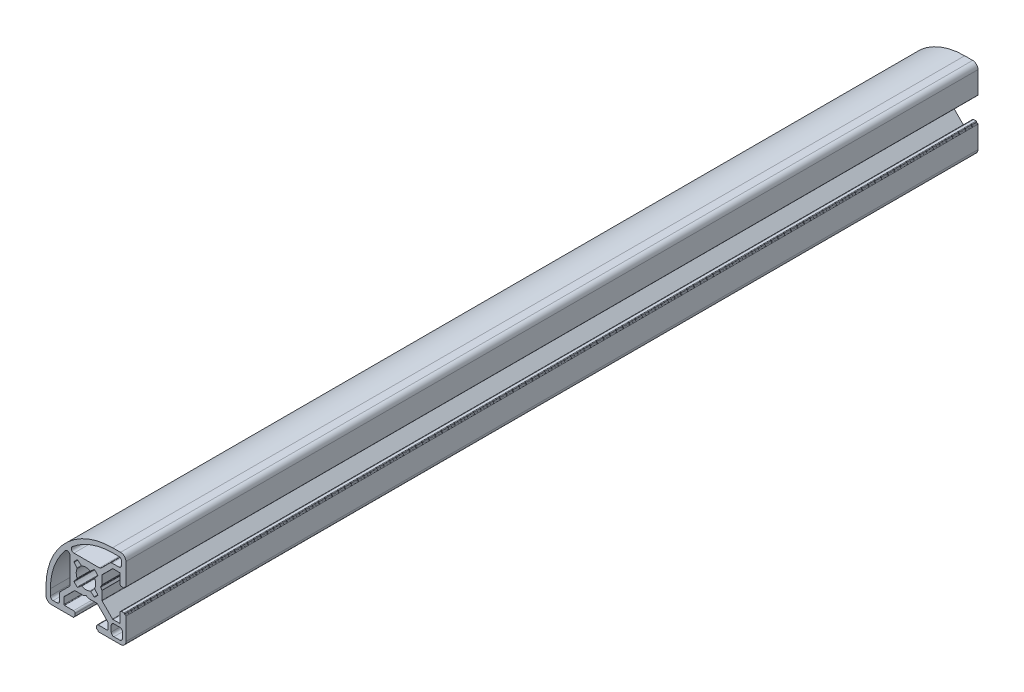
from build123d import *

# Parameters (mm, degrees)
EXTRUDE_1_DEPTH = 320


with BuildPart() as part:
    # Эскиз1 → Бобышка-Вытянуть1 (new body)
    with BuildSketch(Plane.XY):
        with BuildLine():
            Line((5.977671173, -0.853590033), (5.542585895, -0.100000184))
            ThreePointArc((5.542585895, -0.100000184), (5.515790979, -1.84e-07), (5.5425859, 0.099999816))
            Line((5.5425859, 0.099999816), (5.977671215, 0.853589644))
            ThreePointArc((5.977671215, 0.853589644), (5.9976513, 0.901825834), (6.004466136, 0.953589643))
            Line((6.004466136, 0.953589643), (6.004466136, 4.121623186))
            ThreePointArc((6.004466136, 4.121623186), (6.019690232, 4.198159872), (6.063044784, 4.263044541))
            Line((6.063044784, 4.263044541), (9.991421498, 8.191421063))
            ThreePointArc((9.991421498, 8.191421063), (10.056306169, 8.234775612), (10.132842855, 8.249999704))
            Line((10.132842855, 8.249999704), (12.600000143, 8.249999704))
            ThreePointArc((12.600000143, 8.249999704), (12.741421498, 8.191421057), (12.800000138, 8.049999699))
            Line((12.800000138, 8.049999699), (12.800000138, 4.649999699))
            ThreePointArc((12.800000138, 4.649999699), (12.975736059, 4.225735626), (13.400000123, 4.049999684))
            Line((13.400000123, 4.049999684), (14.300000123, 4.049999684))
            ThreePointArc((14.300000123, 4.049999684), (14.441421481, 4.108578325), (14.500000128, 4.249999679))
            Line((14.500000128, 4.249999679), (14.500000128, 4.349999679))
            ThreePointArc((14.500000128, 4.349999679), (14.558578775, 4.491421034), (14.700000133, 4.549999675))
            Line((14.700000133, 4.549999675), (14.800000133, 4.549999675))
            ThreePointArc((14.800000133, 4.549999675), (14.941421467, 4.608578371), (15.000000058, 4.749999749))
            Line((15.000000058, 4.749999749), (15.000000259, 12.999999749))
            ThreePointArc((15.000000259, 12.999999749), (14.414213856, 14.414213326), (13.000000308, 14.999999798))
            Line((13.000000308, 14.999999798), (10.000000308, 14.999999798))
            ThreePointArc((10.000000308, 14.999999798), (-7.6776694, 7.677669758), (-15.000000301, -9.999999593))
            Line((-15.000000301, -9.999999593), (-15.000000301, -12.999999593))
            ThreePointArc((-15.000000301, -12.999999593), (-14.414213898, -14.41421317), (-13.00000035, -14.999999642))
            Line((-13.00000035, -14.999999642), (-4.75000035, -14.999999843))
            ThreePointArc((-4.75000035, -14.999999843), (-4.608578992, -14.941421202), (-4.550000345, -14.799999848))
            Line((-4.550000345, -14.799999848), (-4.550000345, -14.699999848))
            ThreePointArc((-4.550000345, -14.699999848), (-4.491421698, -14.558578493), (-4.35000034, -14.499999852))
            Line((-4.35000034, -14.499999852), (-4.25000034, -14.499999852))
            ThreePointArc((-4.25000034, -14.499999852), (-4.108578982, -14.441421212), (-4.050000335, -14.299999857))
            Line((-4.050000335, -14.299999857), (-4.050000335, -13.399999857))
            ThreePointArc((-4.050000335, -13.399999857), (-4.225736256, -12.975735784), (-4.65000032, -12.799999843))
            Line((-4.65000032, -12.799999843), (-8.05000032, -12.799999843))
            ThreePointArc((-8.05000032, -12.799999843), (-8.191421675, -12.741421195), (-8.250000316, -12.599999838))
            Line((-8.250000316, -12.599999838), (-8.250000316, -10.13284255))
            ThreePointArc((-8.250000316, -10.13284255), (-8.23477622, -10.056305864), (-8.191421668, -9.991421195))
            Line((-8.191421668, -9.991421195), (-4.263044954, -6.063044673))
            ThreePointArc((-4.263044954, -6.063044673), (-4.198160283, -6.019690124), (-4.121623597, -6.004466032))
            Line((-4.121623597, -6.004466032), (-0.953590053, -6.004466032))
            ThreePointArc((-0.953590053, -6.004466032), (-0.901826244, -5.997651199), (-0.853590053, -5.977671116))
            Line((-0.853590053, -5.977671116), (-0.100000204, -5.542585838))
            ThreePointArc((-0.100000204, -5.542585838), (-2.03e-07, -5.515790921), (0.099999796, -5.542585843))
            Line((0.099999796, -5.542585843), (0.853589624, -5.977671157))
            ThreePointArc((0.853589624, -5.977671157), (0.901825815, -5.997651243), (0.953589624, -6.004466079))
            Line((0.953589624, -6.004466079), (4.121623167, -6.004466079))
            ThreePointArc((4.121623167, -6.004466079), (4.198159853, -6.019690174), (4.263044521, -6.063044726))
            Line((4.263044521, -6.063044726), (8.191421044, -9.99142144))
            ThreePointArc((8.191421044, -9.99142144), (8.234775593, -10.056306111), (8.249999684, -10.132842798))
            Line((8.249999684, -10.132842798), (8.249999684, -12.600000085))
            ThreePointArc((8.249999684, -12.600000085), (8.191421037, -12.74142144), (8.04999968, -12.800000081))
            Line((8.04999968, -12.800000081), (4.64999968, -12.800000081))
            ThreePointArc((4.64999968, -12.800000081), (4.225735607, -12.975736002), (4.049999665, -13.400000066))
            Line((4.049999665, -13.400000066), (4.049999665, -14.300000066))
            ThreePointArc((4.049999665, -14.300000066), (4.108578305, -14.441421424), (4.24999966, -14.500000071))
            Line((4.24999966, -14.500000071), (4.34999966, -14.500000071))
            ThreePointArc((4.34999966, -14.500000071), (4.491421015, -14.558578718), (4.549999655, -14.700000076))
            Line((4.549999655, -14.700000076), (4.549999655, -14.800000076))
            ThreePointArc((4.549999655, -14.800000076), (4.608578296, -14.941421433), (4.74999965, -15.000000081))
            Line((4.74999965, -15.000000081), (12.99999965, -15.000000282))
            ThreePointArc((12.99999965, -15.000000282), (14.414213227, -14.414213878), (14.999999699, -13.00000033))
            Line((14.999999699, -13.00000033), (14.9999999, -4.75000033))
            ThreePointArc((14.9999999, -4.75000033), (14.94142126, -4.608578973), (14.799999905, -4.550000325))
            Line((14.799999905, -4.550000325), (14.699999905, -4.550000325))
            ThreePointArc((14.699999905, -4.550000325), (14.55857855, -4.491421678), (14.49999991, -4.350000321))
            Line((14.49999991, -4.350000321), (14.49999991, -4.250000321))
            ThreePointArc((14.49999991, -4.250000321), (14.44142127, -4.108578963), (14.299999915, -4.050000316))
            Line((14.299999915, -4.050000316), (13.399999915, -4.050000316))
            ThreePointArc((13.399999915, -4.050000316), (12.975735842, -4.225736237), (12.7999999, -4.650000301))
            Line((12.7999999, -4.650000301), (12.7999999, -8.050000301))
            ThreePointArc((12.7999999, -8.050000301), (12.741421253, -8.191421656), (12.599999895, -8.250000296))
            Line((12.599999895, -8.250000296), (10.132842608, -8.250000296))
            ThreePointArc((10.132842608, -8.250000296), (10.056305922, -8.234776201), (9.991421253, -8.191421649))
            Line((9.991421253, -8.191421649), (6.06304473, -4.263044935))
            ThreePointArc((6.06304473, -4.263044935), (6.019690182, -4.198160264), (6.00446609, -4.121623577))
            Line((6.00446609, -4.121623577), (6.00446609, -0.953590034))
            ThreePointArc((6.00446609, -0.953590034), (5.997651256, -0.901826225), (5.977671173, -0.853590033))
        make_face()
        with BuildLine():
            Line((-5.995534092, -5.047867784), (-5.995533859, 4.51462478))
            ThreePointArc((-5.995533859, 4.51462478), (-6.649431664, 5.452821624), (-7.755960416, 5.164048743))
            ThreePointArc((-7.755960416, 5.164048743), (-11.906896027, -1.918513974), (-13.350000301, -9.999999675))
            Line((-13.350000301, -9.999999675), (-13.350000301, -12.349999675))
            ThreePointArc((-13.350000301, -12.349999675), (-13.057107099, -13.057106463), (-12.350000325, -13.349999699))
            Line((-12.350000325, -13.349999699), (-10.900000325, -13.349999699))
            ThreePointArc((-10.900000325, -13.349999699), (-10.192893537, -13.057106498), (-9.900000301, -12.349999723))
            Line((-9.900000301, -12.349999723), (-9.900000301, -9.780760908))
            ThreePointArc((-9.900000301, -9.780760908), (-9.823879824, -9.398077477), (-9.607107065, -9.073654134))
            Line((-9.607107065, -9.073654134), (-6.288427328, -5.754974558))
            ThreePointArc((-6.288427328, -5.754974558), (-6.071654568, -5.430551215), (-5.995534092, -5.047867784))
        make_face(mode=Mode.SUBTRACT)
        with BuildLine():
            Line((13.350000208, 10.899999779), (13.350000208, 12.349999779))
            ThreePointArc((13.350000208, 12.349999779), (13.057107017, 13.057106551), (12.350000268, 13.349999798))
            Line((12.350000268, 13.349999798), (10.000000268, 13.349999798))
            ThreePointArc((10.000000268, 13.349999798), (1.918514515, 11.906895909), (-5.164048387, 7.755960646))
            ThreePointArc((-5.164048387, 7.755960646), (-5.452821321, 6.649431908), (-4.51462451, 5.995534058))
            Line((-4.51462451, 5.995534058), (5.047868054, 5.995533825))
            ThreePointArc((5.047868054, 5.995533825), (5.430551489, 6.071654283), (5.754974843, 6.288427026))
            Line((5.754974843, 6.288427026), (9.07365458, 9.607106602))
            ThreePointArc((9.07365458, 9.607106602), (9.398077934, 9.823879345), (9.780761368, 9.899999803))
            Line((9.780761368, 9.899999803), (12.350000184, 9.899999803))
            ThreePointArc((12.350000184, 9.899999803), (13.057106972, 10.192893005), (13.350000208, 10.899999779))
        make_face(mode=Mode.SUBTRACT)
        with BuildLine():
            Line((13.699999744, -10.50000028), (13.699999744, -12.70000028))
            ThreePointArc((13.699999744, -12.70000028), (13.407106508, -13.407107054), (12.69999972, -13.700000256))
            Line((12.69999972, -13.700000256), (10.49999972, -13.700000256))
            ThreePointArc((10.49999972, -13.700000256), (9.792892946, -13.40710702), (9.499999744, -12.700000231))
            Line((9.499999744, -12.700000231), (9.499999744, -10.500000231))
            ThreePointArc((9.499999744, -10.500000231), (9.79289298, -9.792893457), (10.499999769, -9.500000256))
            Line((10.499999769, -9.500000256), (12.699999769, -9.500000256))
            ThreePointArc((12.699999769, -9.500000256), (13.407106543, -9.792893492), (13.699999744, -10.50000028))
        make_face(mode=Mode.SUBTRACT)
        with BuildLine():
            Line((-3.334407305, 1.759211763), (-4.405223013, 3.035360293))
            ThreePointArc((-4.405223013, 3.035360293), (-4.45192881, 3.158076825), (-4.412467484, 3.283310936))
            ThreePointArc((-4.412467484, 3.283310936), (-3.889087202, 3.889087391), (-3.283310721, 4.412467644))
            ThreePointArc((-3.283310721, 4.412467644), (-3.158076608, 4.451928964), (-3.035360078, 4.405223161))
            Line((-3.035360078, 4.405223161), (-1.7592116, 3.334407391))
            ThreePointArc((-1.7592116, 3.334407391), (-1.656657743, 3.289313958), (-1.545944772, 3.306441405))
            ThreePointArc((-1.545944772, 3.306441405), (8.9e-08, 3.65), (1.545944933, 3.306441329))
            ThreePointArc((1.545944933, 3.306441329), (1.656657903, 3.289313878), (1.759211763, 3.334407305))
            Line((1.759211763, 3.334407305), (3.035360293, 4.405223013))
            ThreePointArc((3.035360293, 4.405223013), (3.158076825, 4.45192881), (3.283310936, 4.412467484))
            ThreePointArc((3.283310936, 4.412467484), (3.889087391, 3.889087202), (4.412467644, 3.283310721))
            ThreePointArc((4.412467644, 3.283310721), (4.451928964, 3.158076608), (4.405223161, 3.035360078))
            Line((4.405223161, 3.035360078), (3.334407391, 1.7592116))
            ThreePointArc((3.334407391, 1.7592116), (3.289313958, 1.656657743), (3.306441405, 1.545944772))
            ThreePointArc((3.306441405, 1.545944772), (3.65, -8.9e-08), (3.306441329, -1.545944933))
            ThreePointArc((3.306441329, -1.545944933), (3.289313878, -1.656657903), (3.334407305, -1.759211763))
            Line((3.334407305, -1.759211763), (4.405223013, -3.035360293))
            ThreePointArc((4.405223013, -3.035360293), (4.45192881, -3.158076825), (4.412467484, -3.283310936))
            ThreePointArc((4.412467484, -3.283310936), (3.889087202, -3.889087391), (3.283310721, -4.412467644))
            ThreePointArc((3.283310721, -4.412467644), (3.158076608, -4.451928964), (3.035360078, -4.405223161))
            Line((3.035360078, -4.405223161), (1.7592116, -3.334407391))
            ThreePointArc((1.7592116, -3.334407391), (1.656657743, -3.289313958), (1.545944772, -3.306441405))
            ThreePointArc((1.545944772, -3.306441405), (-8.9e-08, -3.65), (-1.545944933, -3.306441329))
            ThreePointArc((-1.545944933, -3.306441329), (-1.656657903, -3.289313878), (-1.759211763, -3.334407305))
            Line((-1.759211763, -3.334407305), (-3.035360293, -4.405223013))
            ThreePointArc((-3.035360293, -4.405223013), (-3.158076825, -4.45192881), (-3.283310936, -4.412467484))
            ThreePointArc((-3.283310936, -4.412467484), (-3.889087391, -3.889087202), (-4.412467644, -3.283310721))
            ThreePointArc((-4.412467644, -3.283310721), (-4.451928964, -3.158076608), (-4.405223161, -3.035360078))
            Line((-4.405223161, -3.035360078), (-3.334407391, -1.7592116))
            ThreePointArc((-3.334407391, -1.7592116), (-3.289313958, -1.656657743), (-3.306441405, -1.545944772))
            ThreePointArc((-3.306441405, -1.545944772), (-3.65, 8.9e-08), (-3.306441329, 1.545944933))
            ThreePointArc((-3.306441329, 1.545944933), (-3.289313878, 1.656657903), (-3.334407305, 1.759211763))
        make_face(mode=Mode.SUBTRACT)
    extrude(amount=EXTRUDE_1_DEPTH)


solid = part.part
